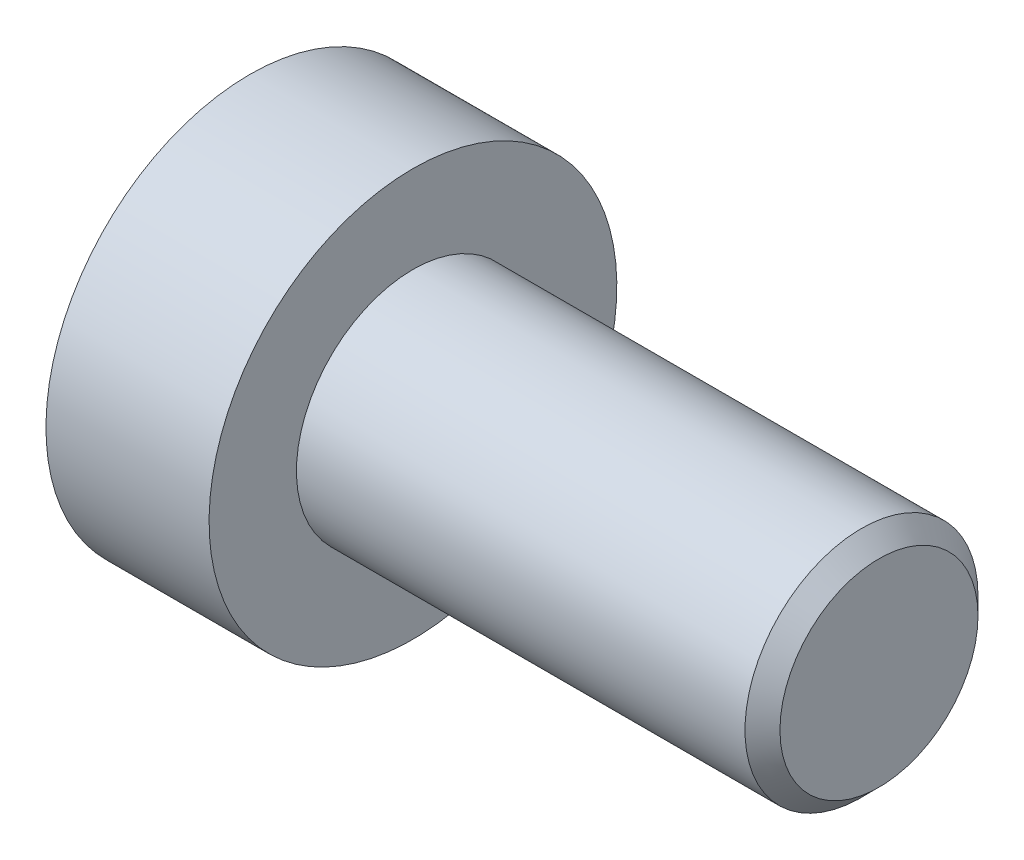
from build123d import *

# Parameters (mm, degrees)
SKETCH2_R           = 2
BOSS_EXTRUDE1_DEPTH = 8
CHAMFER1_SIZE       = 0.3
SKETCH6_W           = 2.8
SKETCH6_H           = 3.5
CUT_EXTRUDE1_DEPTH  = 1.6
SKETCH8_R           = 1.493375673
CUT_EXTRUDE2_DEPTH  = 1
CUT_EXTRUDE2_TAPER  = 45


with BuildPart() as part:
    # Sketch2 → Boss-Extrude1 (new body)
    with BuildSketch(Plane(origin=(0, 0, 0), x_dir=(0, 0, -1), z_dir=(1, 0, 0))):
        Circle(SKETCH2_R)
    extrude(amount=-BOSS_EXTRUDE1_DEPTH)

    # Chamfer1
    chamfer1_edges = [part.edges().sort_by_distance(p)[0] for p in [
        (0, 0, 2),
    ]]
    chamfer(chamfer1_edges, length=CHAMFER1_SIZE)

    # Sketch6 → Revolve1 (revolve)
    with BuildSketch(Plane.XY):
        with Locations((-9.4, 1.75)):
            Rectangle(SKETCH6_W, SKETCH6_H)
    revolve(axis=Axis((-8, 0, 0), (-1, 0, 0)))

    # Sketch7 → Cut-Extrude1 (cut)
    with BuildSketch(Plane.ZY.offset(10.8)):
        Polygon((0, 1.443375673), (-1.25, 0.721687836), (-1.25, -0.721687836), (0, -1.443375673), (1.25, -0.721687836), (1.25, 0.721687836), align=None)
    extrude(amount=-CUT_EXTRUDE1_DEPTH, mode=Mode.SUBTRACT)

    # Sketch8 → Cut-Extrude2 (cut)
    with BuildSketch(Plane.ZY.offset(10.8)):
        Circle(SKETCH8_R)
    extrude(amount=-CUT_EXTRUDE2_DEPTH, taper=CUT_EXTRUDE2_TAPER, mode=Mode.SUBTRACT)


solid = part.part
